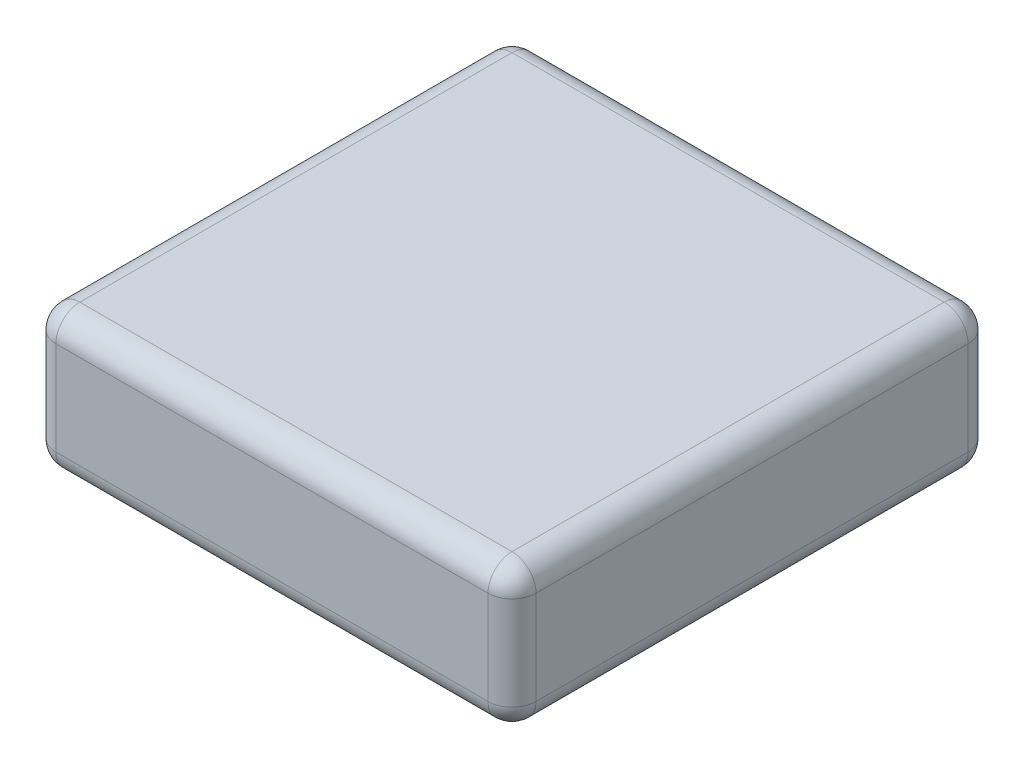
from build123d import *

# Parameters (mm, degrees)
SKETCH1_W           = 50.8
SKETCH1_H           = 50.8
BOSS_EXTRUDE1_DEPTH = 15
FILLET1_R           = 2.54


with BuildPart() as part:
    # Sketch1 → Boss-Extrude1 (new body)
    with BuildSketch(Plane(origin=(0, 0, 0), x_dir=(1, 0, 0), z_dir=(0, 1, 0))):
        with Locations((25.4, 25.4)):
            Rectangle(SKETCH1_W, SKETCH1_H)
    extrude(amount=BOSS_EXTRUDE1_DEPTH)

    # Fillet1
    fillet1_edges = [part.edges().sort_by_distance(p)[0] for p in [
        (50.8, 15, -25.4),
        (25.4, 15, -50.8),
        (0, 15, -25.4),
        (25.4, 0, -50.8),
        (50.8, 0, -25.4),
        (25.4, 0, 0),
        (0, 0, -25.4),
        (0, 7.5, -50.8),
        (50.8, 7.5, -50.8),
        (50.8, 7.5, 0),
        (0, 7.5, 0),
        (25.4, 15, 0),
    ]]
    fillet(fillet1_edges, radius=FILLET1_R)


solid = part.part
